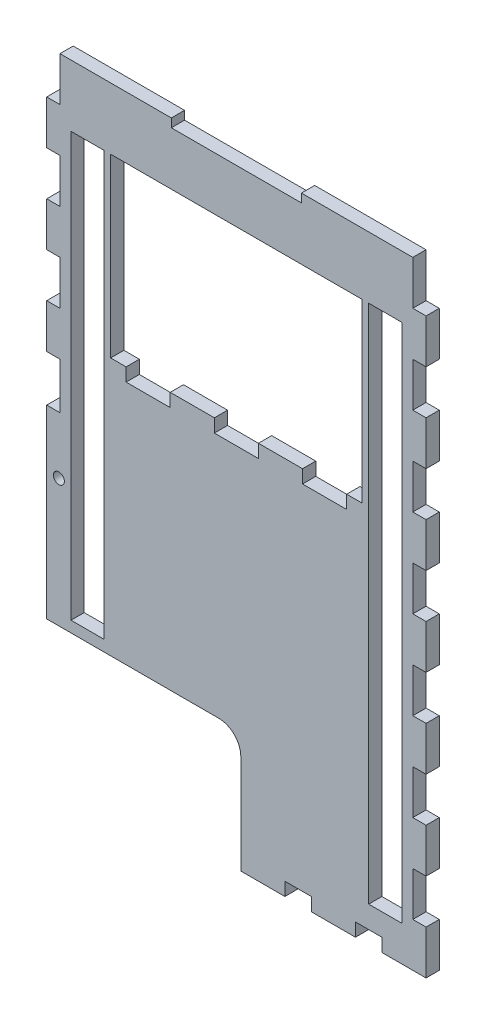
from build123d import *

# Parameters (mm, degrees)
BOSS_EXTRUDE1_DEPTH = 6
SKETCH2_W           = 15
SKETCH2_H           = 192
SKETCH2_H_2         = 236
CUT_EXTRUDE1_DEPTH  = 6
SKETCH3_W           = 114
SKETCH3_H           = 80
CUT_EXTRUDE2_DEPTH  = 6
SKETCH5_W           = 20
SKETCH5_H           = 6
CUT_EXTRUDE5_DEPTH  = 6
SKETCH6_R           = 2.5
CUT_EXTRUDE7_DEPTH  = 6
SKETCH7_W           = 59
SKETCH7_H           = 3.87
CUT_EXTRUDE8_DEPTH  = 6
CUT_EXTRUDE10_DEPTH = 6
SKETCH10_W          = 12
SKETCH10_H          = 6
CUT_EXTRUDE11_DEPTH = 6


with BuildPart() as part:
    # Sketch1 → Boss-Extrude1 (new body)
    with BuildSketch(Plane.XY):
        Polygon((-86, 90.5), (-80, 90.5), (-80, 110.5), (80, 110.5), (80, 90.5), (86, 90.5), (86, 70.5), (80, 70.5), (80, 50.5), (86, 50.5), (86, 30.5), (80, 30.5), (80, 10.5), (86, 10.5), (86, -9.5), (80, -9.5), (80, -29.5), (86, -29.5), (86, -49.5), (80, -49.5), (80, -69.5), (86, -69.5), (86, -89.5), (80, -89.5), (80, -109.5), (86, -109.5), (86, -129.5), (80, -129.5), (80, -149.5), (86, -149.5), (86, -169.5), (80, -169.5), (-86, -169.5), (-86, -30.5), (-80, -30.5), (-80, -9.5), (-86, -9.5), (-86, 10.5), (-80, 10.5), (-80, 30.5), (-86, 30.5), (-86, 50.5), (-80, 50.5), (-80, 70.5), (-86, 70.5), align=None)
    extrude(amount=BOSS_EXTRUDE1_DEPTH)

    # Sketch2 → Cut-Extrude1 (cut)
    with BuildSketch(Plane.XY):
        with Locations((-67.5, -13.5)):
            Rectangle(SKETCH2_W, SKETCH2_H)
        with Locations((67.5, -35.5)):
            Rectangle(SKETCH2_W, SKETCH2_H_2)
    extrude(amount=CUT_EXTRUDE1_DEPTH, mode=Mode.SUBTRACT)

    # Sketch3 → Cut-Extrude2 (cut)
    with BuildSketch(Plane.XY.offset(6)):
        with Locations((0, 42.5)):
            Rectangle(SKETCH3_W, SKETCH3_H)
    extrude(amount=-CUT_EXTRUDE2_DEPTH, mode=Mode.SUBTRACT)

    # Sketch5 → Cut-Extrude5 (cut)
    with BuildSketch(Plane(origin=(0, 0, 0), x_dir=(-1, 0, 0), z_dir=(0, 0, -1))):
        with Locations((40, -0.5)):
            Rectangle(SKETCH5_W, SKETCH5_H)
        with Locations((0, -0.5)):
            Rectangle(SKETCH5_W, SKETCH5_H)
        with Locations((-40, -0.5)):
            Rectangle(SKETCH5_W, SKETCH5_H)
    extrude(amount=-CUT_EXTRUDE5_DEPTH, mode=Mode.SUBTRACT)

    # Sketch6 → Cut-Extrude7 (cut)
    with BuildSketch(Plane.XY.offset(6)):
        with Locations((-80.5, -56.5)):
            Circle(SKETCH6_R)
    extrude(amount=-CUT_EXTRUDE7_DEPTH, mode=Mode.SUBTRACT)

    # Sketch7 → Cut-Extrude8 (cut)
    with BuildSketch(Plane(origin=(0, 0, 0), x_dir=(-1, 0, 0), z_dir=(0, 0, -1))):
        with Locations((0, 108.565)):
            Rectangle(SKETCH7_W, SKETCH7_H)
    extrude(amount=-CUT_EXTRUDE8_DEPTH, mode=Mode.SUBTRACT)

    # Sketch9 → Cut-Extrude10 (cut)
    with BuildSketch(Plane.XY.offset(6)):
        with BuildLine():
            Line((-86, -169.5), (2, -169.5))
            Line((2, -169.5), (2, -124.5))
            ThreePointArc((2, -124.5), (-0.928932188, -117.428932188), (-8, -114.5))
            Line((-8, -114.5), (-86, -114.5))
            Line((-86, -114.5), (-86, -169.5))
        make_face()
    extrude(amount=-CUT_EXTRUDE10_DEPTH, mode=Mode.SUBTRACT)

    # Sketch10 → Cut-Extrude11 (cut)
    with BuildSketch(Plane.XY.offset(6)):
        with Locations((28, -166.5)):
            Rectangle(SKETCH10_W, SKETCH10_H)
        with Locations((60, -166.5)):
            Rectangle(SKETCH10_W, SKETCH10_H)
    extrude(amount=-CUT_EXTRUDE11_DEPTH, mode=Mode.SUBTRACT)


solid = part.part
